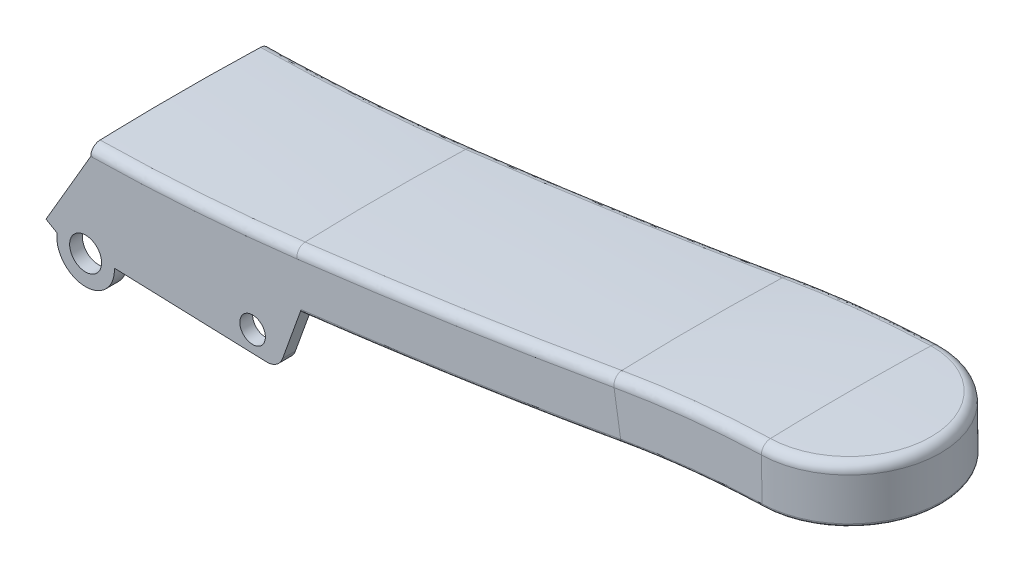
from build123d import *

# Parameters (mm, degrees)
REVOLU_O1_ANGLE          = 180
RESSALTO_EXTRUS_O1_DEPTH = 2
ESBO_O7_R                = 2.5
CORTE_EXTRUS_O1_DEPTH    = 29.0000001
ESBO_O8_R                = 2
CORTE_EXTRUS_O2_DEPTH    = 29.0000001


with BuildPart() as part:
    # Varredura1: sweep along a path in Esboço1
    with BuildLine(Plane.XY) as varredura1_path:
        ThreePointArc((0, 0), (16.529462147, 0.705444386), (33, 2.268183475))
        ThreePointArc((33, 2.268183475), (58.050044629, 5.646181244), (83, 9.697765111))
        ThreePointArc((83, 9.697765111), (93.959586917, 11.235067223), (105, 12))
    # Esboço2 → Varredura1 (sweep)
    with BuildSketch(Plane(origin=(0, 0, 0), x_dir=(0, 0, -1), z_dir=(1, 0, 0))):
        with BuildLine():
            Line((-14, 7.442730927), (-14, 0.894376808))
            ThreePointArc((-14, 0.894376808), (-13.5, 0.394376808), (-13, 0.894376808))
            Line((-13, 0.894376808), (-13, 6.736019744))
            ThreePointArc((-13, 6.736019744), (-12.74508542, 7.380356175), (-12.118337614, 7.675886319))
            ThreePointArc((-12.118337614, 7.675886319), (-6.062261288, 7.966491733), (0, 8.063959997))
            ThreePointArc((0, 8.063959997), (6.062261288, 7.966491733), (12.118337614, 7.675886319))
            ThreePointArc((12.118337614, 7.675886319), (12.74508542, 7.380356175), (13, 6.736019744))
            Line((13, 6.736019744), (13, 0.894376808))
            ThreePointArc((13, 0.894376808), (13.5, 0.394376808), (14, 0.894376808))
            Line((14, 0.894376808), (14, 7.442730927))
            ThreePointArc((14, 7.442730927), (13.576954157, 8.486842866), (12.546440343, 8.942011852))
            ThreePointArc((12.546440343, 8.942011852), (0, 9.136278747), (-12.546440343, 8.942011852))
            ThreePointArc((-12.546440343, 8.942011852), (-13.576954157, 8.486842866), (-14, 7.442730927))
        make_face()
    sweep(path=varredura1_path.line)

    # Esboço3 → Revolução1 (revolve)
    with BuildSketch(Plane(origin=(105.176984905, 1.830436311, 0), x_dir=(0, 0, -1), z_dir=(0.999848595, 0.017400757, 0))):
        with BuildLine():
            Line((14, 17.613834568), (14, 11.065480449))
            ThreePointArc((14, 11.065480449), (13.5, 10.565480449), (13, 11.065480449))
            Line((13, 11.065480449), (13, 16.907123386))
            ThreePointArc((13, 16.907123386), (12.74508542, 17.551459816), (12.118337614, 17.84698996))
            ThreePointArc((12.118337614, 17.84698996), (6.062261288, 18.137595374), (0, 18.235063639))
            Line((0, 18.235063639), (0, 19.307382388))
            ThreePointArc((0, 19.307382388), (6.273972125, 19.258812754), (12.546440343, 19.113115494))
            ThreePointArc((12.546440343, 19.113115494), (13.576954157, 18.657946508), (14, 17.613834568))
        make_face()
    revolve(axis=Axis((104.841021832, 21.134895472, 0), (0.017400757, -0.999848595, 0)), revolution_arc=REVOLU_O1_ANGLE)

    # Esboço6 → Ressalto-extrusão1 (add)
    with BuildSketch(Plane.XY.offset(14)):
        with BuildLine():
            Line((0, 7.442730927), (-7, -4.557269073))
            Line((-7, -4.557269073), (-5.272442198, -5.565011124))
            ThreePointArc((-5.272442198, -5.565011124), (-0.943881137, -10.614607271), (3.685022716, -5.838823437))
            Line((3.685022716, -5.838823437), (27.464771889, -6.644799062))
            ThreePointArc((27.464771889, -6.644799062), (29.011913143, -6.198294277), (29.999382133, -4.926320387))
            Line((29.999382133, -4.926320387), (32.907249231, 3.157737954))
            Line((32.907249231, 3.157737954), (32.2281564, 9.670784444))
            ThreePointArc((32.2281564, 9.670784444), (16.14315941, 8.136106307), (0, 7.442730927))
        make_face()
    ressalto_extrus_o1 = extrude(amount=-RESSALTO_EXTRUS_O1_DEPTH)

    # Espelhar1: Ressalto-extrusão1 across plane
    add(ressalto_extrus_o1.mirror(Plane.XY))

    # Esboço7 → Corte-extrusão1 (cut, through all)
    with BuildSketch(Plane.XY.offset(14)):
        with Locations((-0.806389095, -6.116708213)):
            Circle(ESBO_O7_R)
    extrude(amount=-CORTE_EXTRUS_O1_DEPTH, mode=Mode.SUBTRACT)

    # Esboço8 → Corte-extrusão2 (cut, through all)
    with BuildSketch(Plane.XY.offset(14)):
        with Locations((25.307249231, -3.369835879)):
            Circle(ESBO_O8_R)
    extrude(amount=-CORTE_EXTRUS_O2_DEPTH, mode=Mode.SUBTRACT)


solid = part.part
